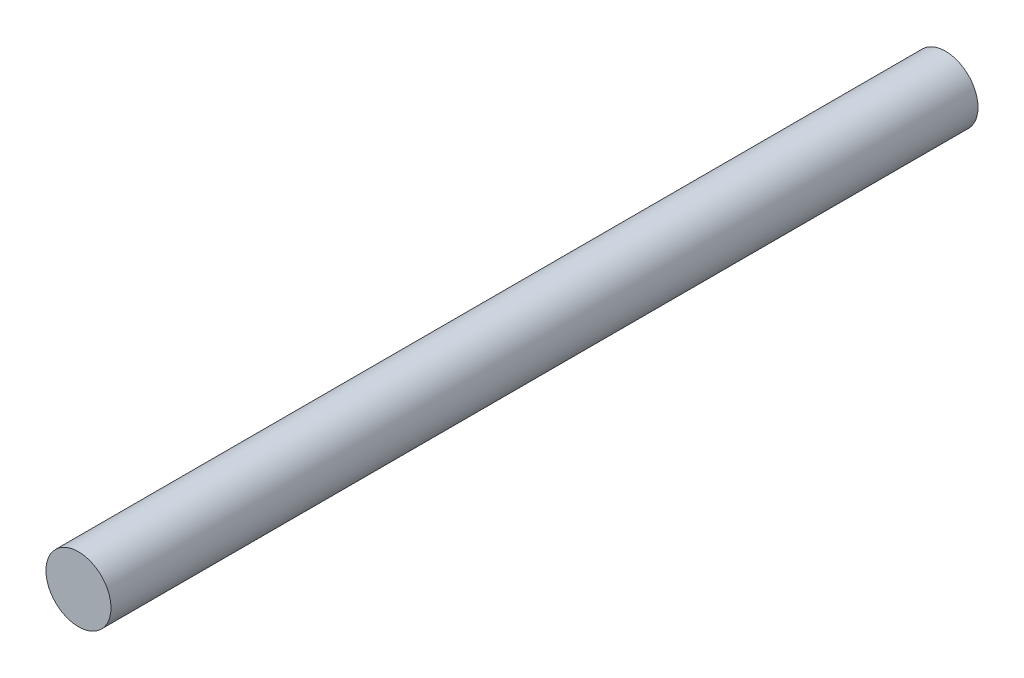
from build123d import *

# Parameters (mm, degrees)
SKETCH1_R           = 1.5
BOSS_EXTRUDE1_DEPTH = 40


with BuildPart() as part:
    # Sketch1 → Boss-Extrude1 (new body)
    with BuildSketch(Plane.XY):
        Circle(SKETCH1_R)
    extrude(amount=BOSS_EXTRUDE1_DEPTH)


solid = part.part
